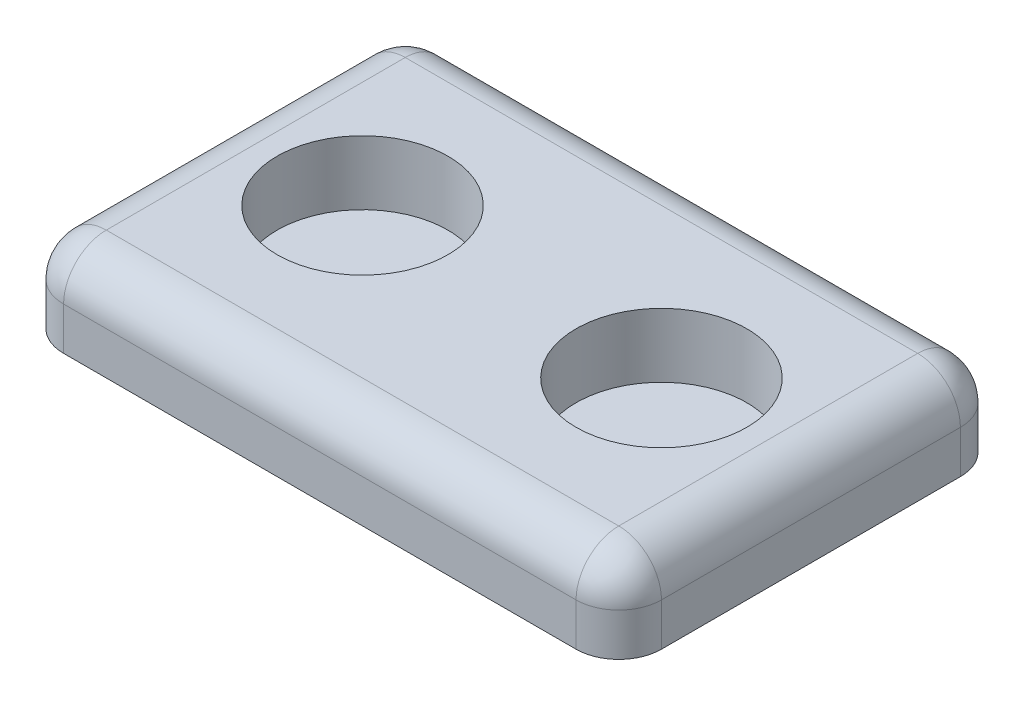
from build123d import *

# Parameters (mm, degrees)
SKETCH1_W           = 140
SKETCH1_H           = 90
BOSS_EXTRUDE1_DEPTH = 20
SKETCH2_R           = 20
CUT_EXTRUDE1_DEPTH  = 15
FILLET1_R           = 10
FILLET2_R           = 10


with BuildPart() as part:
    # Sketch1 → Boss-Extrude1 (new body)
    with BuildSketch(Plane(origin=(0, 0, 0), x_dir=(1, 0, 0), z_dir=(0, 1, 0))):
        Rectangle(SKETCH1_W, SKETCH1_H)
    extrude(amount=BOSS_EXTRUDE1_DEPTH)

    # Sketch2 → Cut-Extrude1 (cut)
    with BuildSketch(Plane(origin=(0, 20, 0), x_dir=(1, 0, 0), z_dir=(0, 1, 0))):
        with Locations((-35, 0)):
            Circle(SKETCH2_R)
        with Locations((35, 0)):
            Circle(SKETCH2_R)
    extrude(amount=-CUT_EXTRUDE1_DEPTH, mode=Mode.SUBTRACT)

    # Fillet1
    fillet1_edges = [part.edges().sort_by_distance(p)[0] for p in [
        (-70, 10, -45),
        (70, 10, -45),
        (70, 10, 45),
        (-70, 10, 45),
    ]]
    fillet(fillet1_edges, radius=FILLET1_R)

    # Fillet2
    fillet2_edges = [part.edges().sort_by_distance(p)[0] for p in [
        (70, 20, 0),
        (0, 20, 45),
        (-70, 20, 0),
        (0, 20, -45),
        (-67.071067812, 20, 42.071067812),
        (-67.071067812, 20, -42.071067812),
        (67.071067812, 20, -42.071067812),
        (67.071067812, 20, 42.071067812),
    ]]
    fillet(fillet2_edges, radius=FILLET2_R)


solid = part.part
